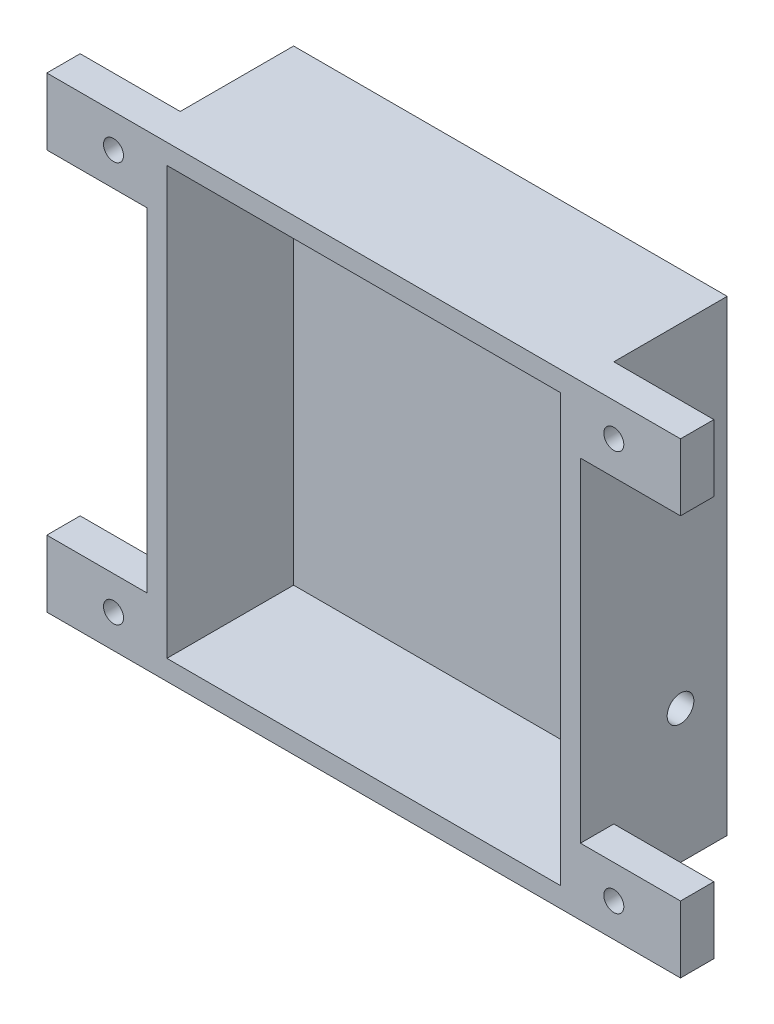
from build123d import *

# Parameters (mm, degrees)
SKETCH1_W           = 59
SKETCH1_H           = 64
BOSS_EXTRUDE1_DEPTH = 19
SHELL1_T            = 3
SKETCH2_R           = 2
CUT_EXTRUDE1_DEPTH  = 19
SKETCH3_W           = 5
SKETCH3_H           = 10
BOSS_EXTRUDE2_DEPTH = 15
SKETCH4_W           = 5
SKETCH4_H           = 10
BOSS_EXTRUDE3_DEPTH = 15
SKETCH5_R           = 1.5
CUT_EXTRUDE2_DEPTH  = 10


with BuildPart() as part:
    # Sketch1 → Boss-Extrude1 (new body)
    with BuildSketch(Plane.XY):
        with Locations((29.5, 32)):
            Rectangle(SKETCH1_W, SKETCH1_H)
    extrude(amount=BOSS_EXTRUDE1_DEPTH)

    # Shell1
    shell1_openings = [part.faces().sort_by_distance(p)[0] for p in [
        (29.5, 32, 19),
    ]]
    offset(amount=SHELL1_T, openings=shell1_openings, kind=Kind.INTERSECTION)

    # Sketch2 → Cut-Extrude1 (cut)
    with BuildSketch(Plane(origin=(62, 0, 0), x_dir=(0, 0, -1), z_dir=(1, 0, 0))):
        with Locations((-4, 17)):
            Circle(SKETCH2_R)
    extrude(amount=-CUT_EXTRUDE1_DEPTH, mode=Mode.SUBTRACT)

    # Sketch3 → Boss-Extrude2 (add)
    with BuildSketch(Plane(origin=(62, 0, 0), x_dir=(0, 0, -1), z_dir=(1, 0, 0))):
        with Locations((-16.5, 62)):
            Rectangle(SKETCH3_W, SKETCH3_H)
        with Locations((-16.5, 2)):
            Rectangle(SKETCH3_W, SKETCH3_H)
    extrude(amount=BOSS_EXTRUDE2_DEPTH)

    # Sketch4 → Boss-Extrude3 (add)
    with BuildSketch(Plane.ZY.offset(3)):
        with Locations((16.5, 2)):
            Rectangle(SKETCH4_W, SKETCH4_H)
        with Locations((16.5, 62)):
            Rectangle(SKETCH4_W, SKETCH4_H)
    extrude(amount=BOSS_EXTRUDE3_DEPTH)

    # Sketch5 → Cut-Extrude2 (cut)
    with BuildSketch(Plane(origin=(0, 0, 14), x_dir=(-1, 0, 0), z_dir=(0, 0, -1))):
        with Locations((-67, 62)):
            Circle(SKETCH5_R)
        with Locations((8, 2)):
            Circle(SKETCH5_R)
        with Locations((-67, 2)):
            Circle(SKETCH5_R)
        with Locations((8, 62)):
            Circle(SKETCH5_R)
    extrude(amount=-CUT_EXTRUDE2_DEPTH, mode=Mode.SUBTRACT)


solid = part.part
